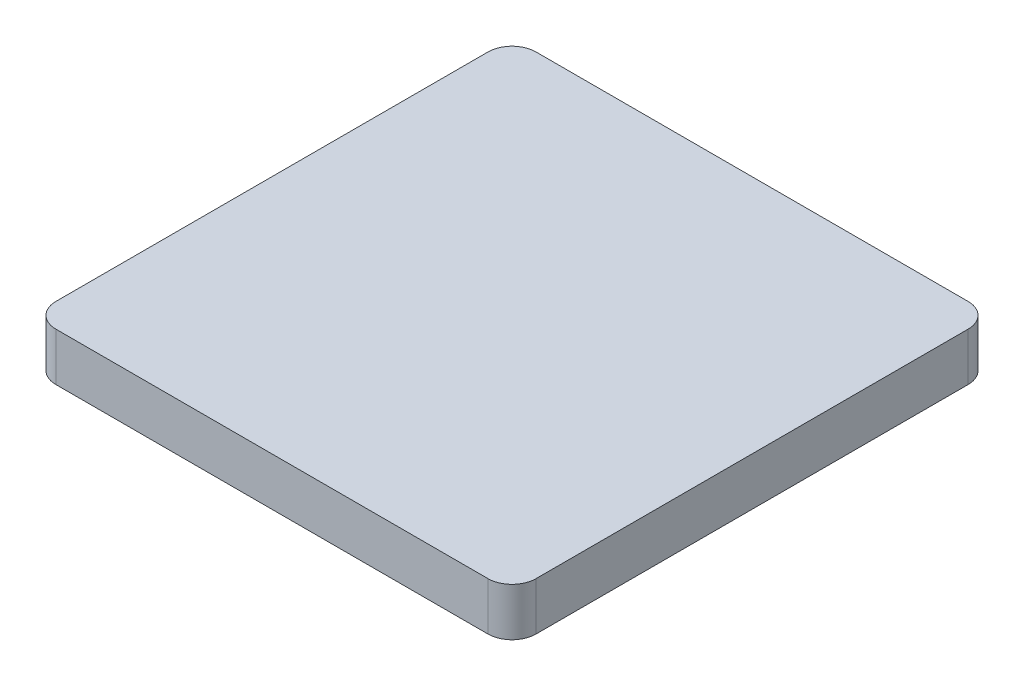
from build123d import *

# Parameters (mm, degrees)
SKETCH2_W           = 60
SKETCH2_H           = 60
BOSS_EXTRUDE1_DEPTH = 6
FILLET1_R           = 3


with BuildPart() as part:
    # Sketch2 → Boss-Extrude1 (new body)
    with BuildSketch(Plane(origin=(0, 0, 0), x_dir=(1, 0, 0), z_dir=(0, 1, 0))):
        with Locations((30, 30)):
            Rectangle(SKETCH2_W, SKETCH2_H)
    extrude(amount=BOSS_EXTRUDE1_DEPTH)

    # Fillet1
    fillet1_edges = [part.edges().sort_by_distance(p)[0] for p in [
        (0, 3, -60),
        (60, 3, -60),
        (60, 3, 0),
        (0, 3, 0),
    ]]
    fillet(fillet1_edges, radius=FILLET1_R)


solid = part.part
